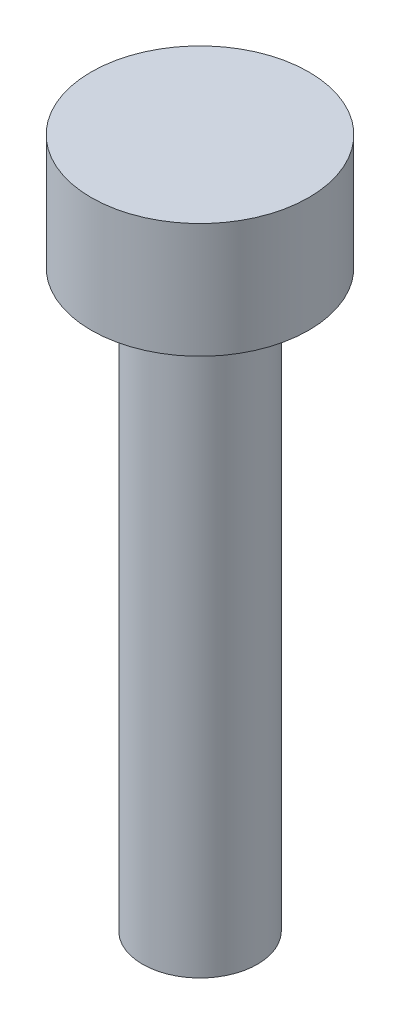
from build123d import *

# Parameters (mm, degrees)
CROQUIS1_R              = 1.5
SALIENTE_EXTRUIR1_DEPTH = 15
CROQUIS2_R              = 2.84
SALIENTE_EXTRUIR2_DEPTH = 3


with BuildPart() as part:
    # Croquis1 → Saliente-Extruir1 (new body)
    with BuildSketch(Plane(origin=(0, 0, 0), x_dir=(1, 0, 0), z_dir=(0, 1, 0))):
        Circle(CROQUIS1_R)
    extrude(amount=SALIENTE_EXTRUIR1_DEPTH)

    # Croquis2 → Saliente-Extruir2 (add)
    with BuildSketch(Plane(origin=(0, 15, 0), x_dir=(1, 0, 0), z_dir=(0, 1, 0))):
        Circle(CROQUIS2_R)
    extrude(amount=SALIENTE_EXTRUIR2_DEPTH)


solid = part.part
